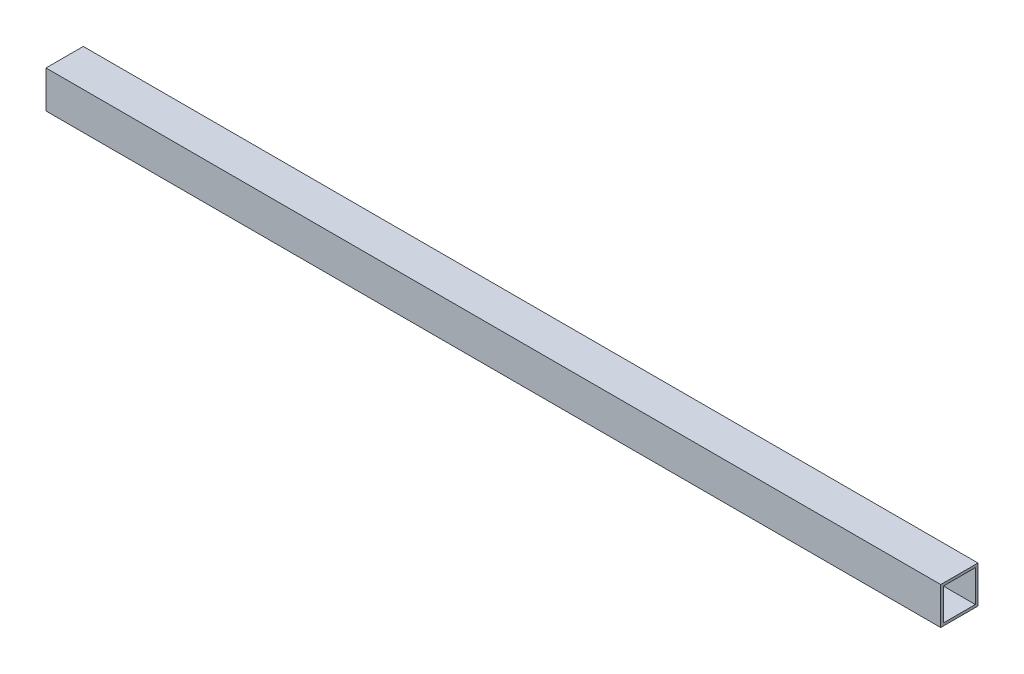
from build123d import *

# Parameters (mm, degrees)
SKETCH1_W           = 44.45
SKETCH1_H           = 44.45
SKETCH1_W_2         = 38.1
SKETCH1_H_2         = 38.1
BOSS_EXTRUDE1_DEPTH = 1066.8


with BuildPart() as part:
    # Sketch1 → Boss-Extrude1 (new body)
    with BuildSketch(Plane(origin=(0, 0, 0), x_dir=(0, 0, -1), z_dir=(1, 0, 0))):
        with Locations((22.225, 22.225)):
            Rectangle(SKETCH1_W, SKETCH1_H)
        with Locations((22.225, 22.225)):
            Rectangle(SKETCH1_W_2, SKETCH1_H_2, mode=Mode.SUBTRACT)
    extrude(amount=BOSS_EXTRUDE1_DEPTH)


solid = part.part
